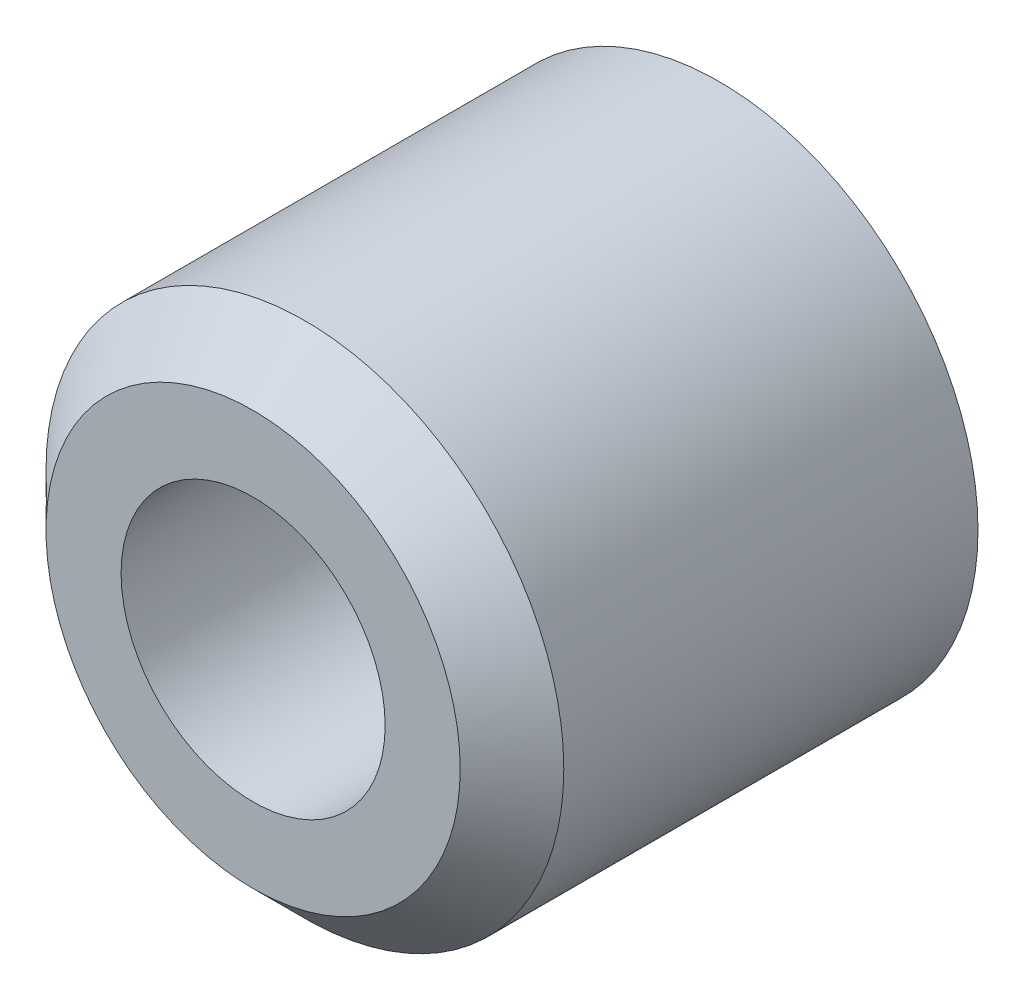
from build123d import *

# Parameters (mm, degrees)
SKETCH_1_R    = 5
SKETCH_1_R_2  = 2.55
BASE_DEPTH    = 9
CHAMFER1_SIZE = 1


with BuildPart() as part:
    # Эскиз1 → Base (new body)
    with BuildSketch(Plane.XY):
        Circle(SKETCH_1_R)
        Circle(SKETCH_1_R_2, mode=Mode.SUBTRACT)
    extrude(amount=BASE_DEPTH)

    # Chamfer1
    chamfer1_edges = [part.edges().sort_by_distance(p)[0] for p in [
        (-5, 0, 9),
    ]]
    chamfer(chamfer1_edges, length=CHAMFER1_SIZE)


solid = part.part
